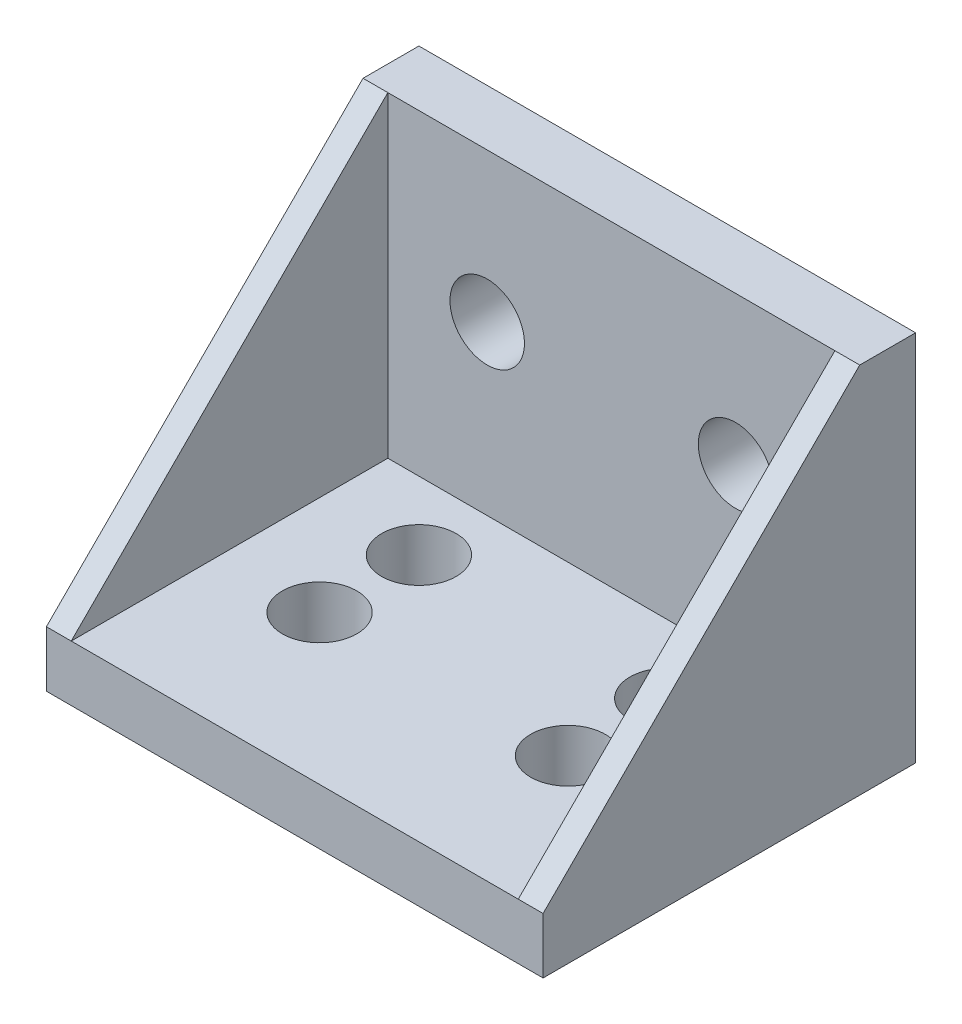
from build123d import *

# Parameters (mm, degrees)
BOSS_EXTRUDE1_DEPTH = 20
SKETCH2_R           = 3
CUT_EXTRUDE1_DEPTH  = 5.5
SKETCH3_R           = 3
CUT_EXTRUDE2_DEPTH  = 5.5
BOSS_EXTRUDE2_DEPTH = 2
BOSS_EXTRUDE3_DEPTH = 2


with BuildPart() as part:
    # Sketch1 → Boss-Extrude1 (new body, symmetric)
    with BuildSketch(Plane(origin=(0, 0, 0), x_dir=(0, 0, -1), z_dir=(1, 0, 0))):
        Polygon((0, 0), (0, 30), (-4.5, 30), (-4.5, 4.5), (-30, 4.5), (-30, 0), align=None)
    extrude(amount=BOSS_EXTRUDE1_DEPTH, both=True)

    # Sketch2 → Cut-Extrude1 (cut, through all)
    with BuildSketch(Plane.XY.offset(4.5)):
        with Locations((-10, 18)):
            Circle(SKETCH2_R)
        with Locations((10, 18)):
            Circle(SKETCH2_R)
    extrude(amount=-CUT_EXTRUDE1_DEPTH, mode=Mode.SUBTRACT)

    # Sketch3 → Cut-Extrude2 (cut, through all)
    with BuildSketch(Plane(origin=(0, 4.5, 0), x_dir=(1, 0, 0), z_dir=(0, 1, 0))):
        with Locations((-10, -10)):
            Circle(SKETCH3_R)
        with Locations((-10, -18)):
            Circle(SKETCH3_R)
        with Locations((10, -10)):
            Circle(SKETCH3_R)
        with Locations((10, -18)):
            Circle(SKETCH3_R)
    extrude(amount=-CUT_EXTRUDE2_DEPTH, mode=Mode.SUBTRACT)

    # Sketch4 → Boss-Extrude2 (add)
    with BuildSketch(Plane(origin=(20, 0, 0), x_dir=(0, 0, -1), z_dir=(1, 0, 0))):
        Polygon((0, 0), (0, 30), (-4.5, 30), (-30, 4.5), (-30, 0), align=None)
    extrude(amount=-BOSS_EXTRUDE2_DEPTH)

    # Sketch5 → Boss-Extrude3 (add)
    with BuildSketch(Plane.ZY.offset(20)):
        Polygon((30, 4.5), (4.5, 30), (4.5, 4.5), align=None)
    extrude(amount=-BOSS_EXTRUDE3_DEPTH)


solid = part.part
